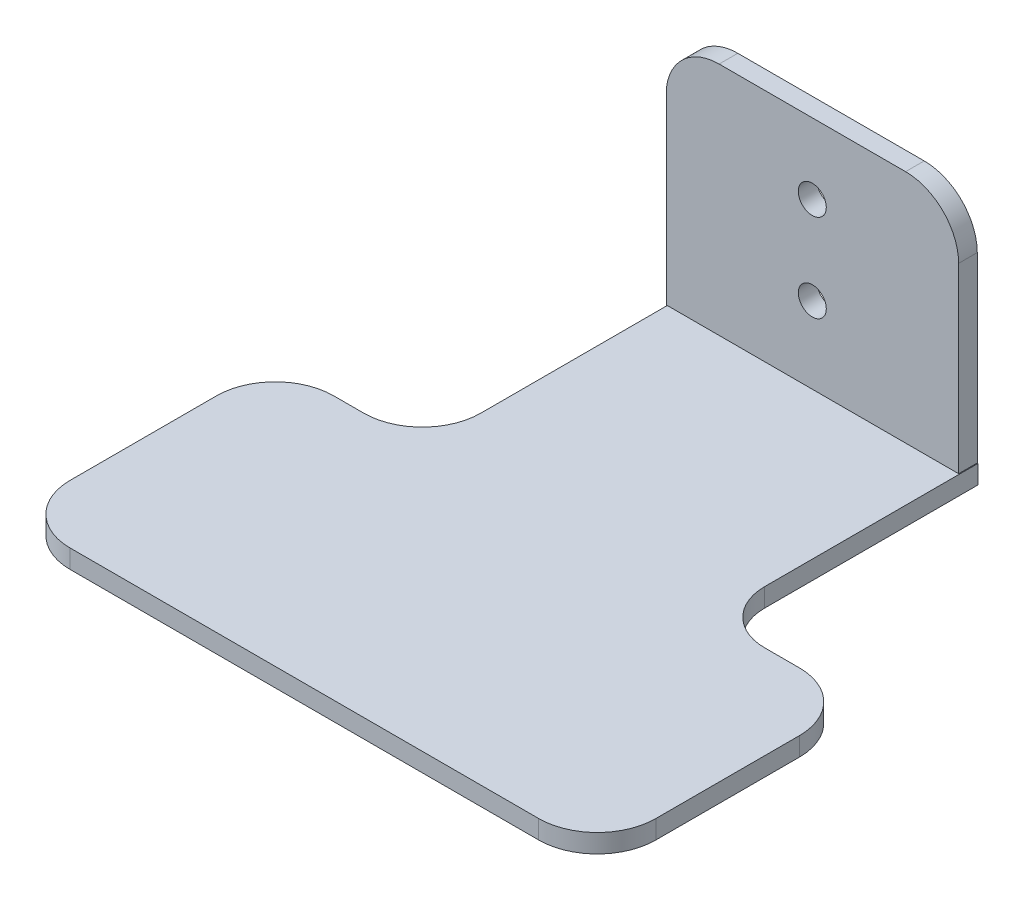
from build123d import *

# Parameters (mm, degrees)
SKETCH4_R           = 2.39
BOSS_EXTRUDE4_DEPTH = 3.18
BOSS_EXTRUDE5_DEPTH = 3.18


with BuildPart() as part:
    # Sketch4 → Boss-Extrude4 (new body)
    with BuildSketch(Plane.XY):
        with BuildLine():
            Line((-17.925296466, 35.419639483), (-17.925296466, 0.349476153))
            Line((-17.925296466, 0.349476153), (31.944623299, 0.349476153))
            Line((31.944623299, 0.349476153), (31.944623299, 34.287104082))
            ThreePointArc((31.944623299, 34.287104082), (29.279371809, 40.670159183), (22.886251145, 43.311175294))
            Line((22.886251145, 43.311175294), (-8.942333261, 43.311175294))
            ThreePointArc((-8.942333261, 43.311175294), (-14.920835694, 41.058088475), (-17.925296466, 35.419639483))
        make_face()
        with Locations((6.958119852, 31.252737949)):
            Circle(SKETCH4_R, mode=Mode.SUBTRACT)
        with Locations((6.958119852, 16.252738122)):
            Circle(SKETCH4_R, mode=Mode.SUBTRACT)
    extrude(amount=BOSS_EXTRUDE4_DEPTH)

    # Sketch2 → Boss-Extrude5 (add)
    with BuildSketch(Plane(origin=(0, 0, 0), x_dir=(1, 0, 0), z_dir=(0, 1, 0))):
        with BuildLine():
            Line((41.133140879, -45.477323382), (47.074703534, -45.477323382))
            ThreePointArc((47.074703534, -45.477323382), (54.145771346, -48.40625557), (57.074703534, -55.477323382))
            Line((57.074703534, -55.477323382), (57.074703534, -80.006057453))
            ThreePointArc((57.074703534, -80.006057453), (54.145771346, -87.077125264), (47.074703534, -90.006057453))
            Line((47.074703534, -90.006057453), (-32.925296466, -90.006057453))
            ThreePointArc((-32.925296466, -90.006057453), (-39.996364277, -87.077125264), (-42.925296466, -80.006057453))
            Line((-42.925296466, -80.006057453), (-42.925296466, -55.006057453))
            ThreePointArc((-42.925296466, -55.006057453), (-39.996364277, -47.934989641), (-32.925296466, -45.006057453))
            Line((-32.925296466, -45.006057453), (-27.800216568, -45.006057453))
            ThreePointArc((-27.800216568, -45.006057453), (-20.729148756, -42.077125264), (-17.800216568, -35.006057453))
            Line((-17.800216568, -35.006057453), (-17.800216568, -0.006057453))
            Line((-17.800216568, -0.006057453), (32.074703534, -0.006057453))
            Line((32.074703534, -0.006057453), (32.074703534, -36.418886037))
            ThreePointArc((32.074703534, -36.418886037), (34.727858406, -42.824168511), (41.133140879, -45.477323382))
        make_face()
    extrude(amount=BOSS_EXTRUDE5_DEPTH)


solid = part.part
